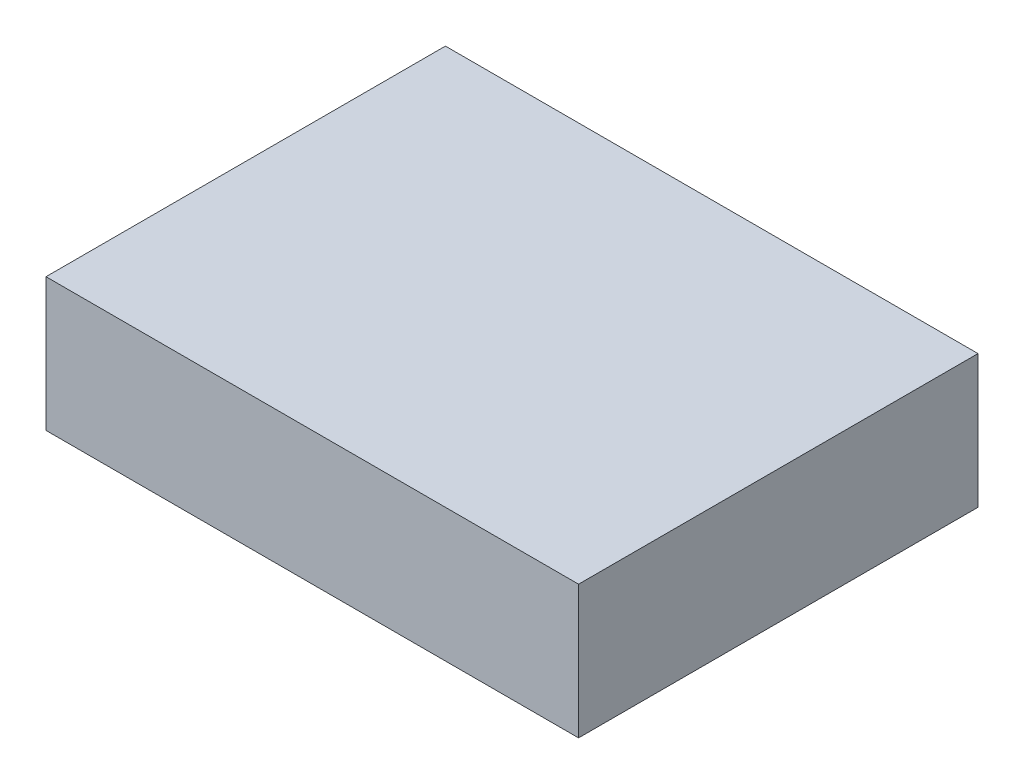
from build123d import *

# Parameters (mm, degrees)
SKETCH1_W           = 400
SKETCH1_H           = 300
BOSS_EXTRUDE1_DEPTH = 100


with BuildPart() as part:
    # Sketch1 → Boss-Extrude1 (new body)
    with BuildSketch(Plane(origin=(0, 0, 0), x_dir=(1, 0, 0), z_dir=(0, 1, 0))):
        with Locations((49.528301887, 1.41509434)):
            Rectangle(SKETCH1_W, SKETCH1_H)
    extrude(amount=BOSS_EXTRUDE1_DEPTH)


solid = part.part
